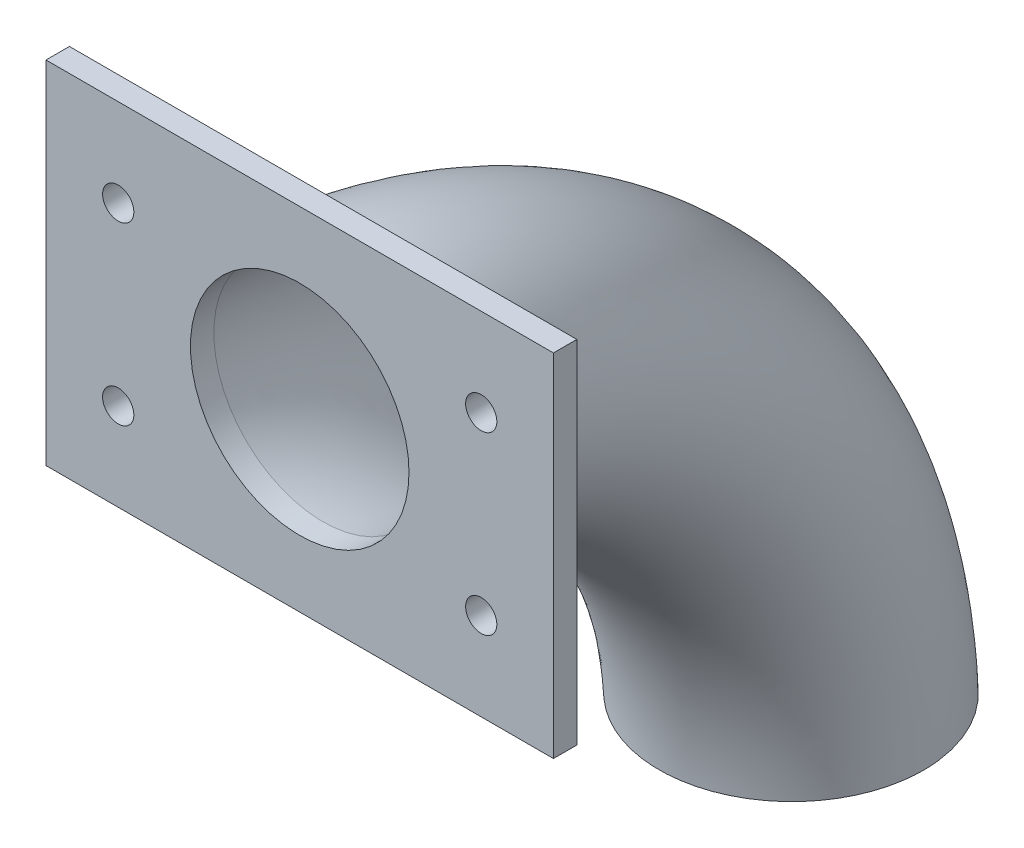
from build123d import *

# Parameters (mm, degrees)
ESQUISSE1_R             = 17
ESQUISSE1_R_2           = 14
ESQUISSE3_W             = 65
ESQUISSE3_H             = 45
ESQUISSE3_R             = 14
ESQUISSE3_R_2           = 2
BOSS_EXTRU_1_DEPTH      = 3
ESQUISSE4_W             = 56.431647226
ESQUISSE4_H             = 36.329386627
ENL_V_MAT_EXTRU_1_DEPTH = 10


with BuildPart() as part:
    # Balayage1: sweep along a path in Esquisse2
    with BuildLine(Plane(origin=(0, 0, 0), x_dir=(0, 0, -1), z_dir=(1, 0, 0))) as balayage1_path:
        ThreePointArc((0, 0), (42.265649833, -21.177861693), (60, -65))
    # Esquisse1 → Balayage1 (sweep)
    with BuildSketch(Plane.XY):
        Circle(ESQUISSE1_R)
        Circle(ESQUISSE1_R_2, mode=Mode.SUBTRACT)
    sweep(path=balayage1_path.line)

    # Esquisse3 → Boss.-Extru.1 (add)
    with BuildSketch(Plane.XY):
        Rectangle(ESQUISSE3_W, ESQUISSE3_H)
        Circle(ESQUISSE3_R, mode=Mode.SUBTRACT)
        with Locations((-23.25, 11.25)):
            Circle(ESQUISSE3_R_2, mode=Mode.SUBTRACT)
        with Locations((-23.25, -11.25)):
            Circle(ESQUISSE3_R_2, mode=Mode.SUBTRACT)
        with Locations((23.25, -11.25)):
            Circle(ESQUISSE3_R_2, mode=Mode.SUBTRACT)
        with Locations((23.25, 11.25)):
            Circle(ESQUISSE3_R_2, mode=Mode.SUBTRACT)
    extrude(amount=BOSS_EXTRU_1_DEPTH)

    # Esquisse4 → Enlèv. mat.-Extru.1 (cut)
    with BuildSketch(Plane(origin=(0, -63, 0), x_dir=(1, 0, 0), z_dir=(0, 1, 0))):
        with Locations((0, 60.039216013)):
            Rectangle(ESQUISSE4_W, ESQUISSE4_H)
    extrude(amount=-ENL_V_MAT_EXTRU_1_DEPTH, mode=Mode.SUBTRACT)


solid = part.part
